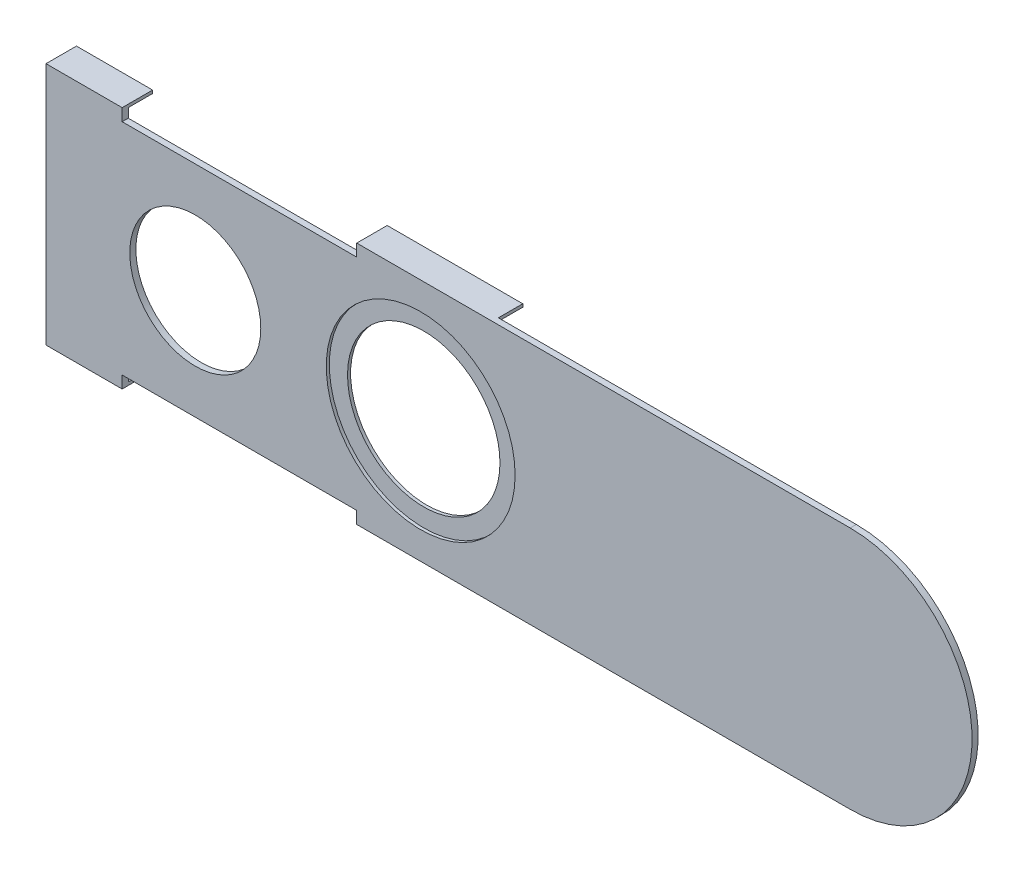
from build123d import *

# Parameters (mm, degrees)
BOSS_EXTRUDE1_DEPTH = 0.508
SKETCH2_R           = 7.874
SKETCH2_R_2         = 6.35
CUT_EXTRUDE2_DEPTH  = 0.254
SKETCH5_R           = 6.354160617
CUT_EXTRUDE3_DEPTH  = 68.821805137
SKETCH6_R           = 5.461
CUT_EXTRUDE4_DEPTH  = 68.821805137
SKETCH7_W           = 19.558
SKETCH7_H           = 1.016
CUT_EXTRUDE5_DEPTH  = 68.823232008
SKETCH8_W           = 6.35
SKETCH8_H           = 0.254
BOSS_EXTRUDE2_DEPTH = 2.032
SKETCH10_W          = 11.303182767
SKETCH10_H          = 0.254
BOSS_EXTRUDE3_DEPTH = 2.032
SKETCH11_W          = 6.35
SKETCH11_H          = 0.254
BOSS_EXTRUDE4_DEPTH = 2.032
SKETCH12_W          = 11.938
SKETCH12_H          = 0.254
BOSS_EXTRUDE5_DEPTH = 2.032
SKETCH13_R          = 7.874
CUT_EXTRUDE7_DEPTH  = 0.254
SKETCH14_R          = 7.874
SKETCH14_R_2        = 5.461
BOSS_EXTRUDE8_DEPTH = 0.254


with BuildPart() as part:
    # Sketch1 → Boss-Extrude1 (new body)
    with BuildSketch(Plane.XY):
        with BuildLine():
            ThreePointArc((0, -10.16), (10.16, 0), (0, 10.16))
            Line((0, 10.16), (-67.056, 10.16))
            Line((-67.056, 10.16), (-67.056, -10.16))
            Line((-67.056, -10.16), (0, -10.16))
        make_face()
    extrude(amount=BOSS_EXTRUDE1_DEPTH)

    # Sketch2 → Cut-Extrude2 (cut)
    with BuildSketch(Plane.XY.offset(0.508)):
        with Locations((-54.61, 0)):
            Circle(SKETCH2_R)
        with Locations((-35.814, 0)):
            Circle(SKETCH2_R_2)
    extrude(amount=-CUT_EXTRUDE2_DEPTH, mode=Mode.SUBTRACT)

    # Sketch5 → Cut-Extrude3 (cut, through all)
    with BuildSketch(Plane.XY.offset(0.254)):
        with Locations((-35.814, 0)):
            Circle(SKETCH5_R)
    extrude(amount=-CUT_EXTRUDE3_DEPTH, mode=Mode.SUBTRACT)

    # Sketch6 → Cut-Extrude4 (cut, through all)
    with BuildSketch(Plane.XY.offset(0.254)):
        with Locations((-54.61, 0)):
            Circle(SKETCH6_R)
    extrude(amount=-CUT_EXTRUDE4_DEPTH, mode=Mode.SUBTRACT)

    # Sketch7 → Cut-Extrude5 (cut, through all)
    with BuildSketch(Plane(origin=(0, 0, 0), x_dir=(-1, 0, 0), z_dir=(0, 0, -1))):
        with Locations((50.927, 9.652)):
            Rectangle(SKETCH7_W, SKETCH7_H)
        with Locations((50.927, -9.652)):
            Rectangle(SKETCH7_W, SKETCH7_H)
    extrude(amount=-CUT_EXTRUDE5_DEPTH, mode=Mode.SUBTRACT)

    # Sketch8 → Boss-Extrude2 (add)
    with BuildSketch(Plane(origin=(0, 0, 0), x_dir=(-1, 0, 0), z_dir=(0, 0, -1))):
        with Locations((63.881, 10.033)):
            Rectangle(SKETCH8_W, SKETCH8_H)
    extrude(amount=BOSS_EXTRUDE2_DEPTH)

    # Sketch10 → Boss-Extrude3 (add)
    with BuildSketch(Plane(origin=(0, 0, 0), x_dir=(-1, 0, 0), z_dir=(0, 0, -1))):
        with Locations((35.496408617, 10.033)):
            Rectangle(SKETCH10_W, SKETCH10_H)
    extrude(amount=BOSS_EXTRUDE3_DEPTH)

    # Sketch11 → Boss-Extrude4 (add)
    with BuildSketch(Plane(origin=(0, 0, 0), x_dir=(-1, 0, 0), z_dir=(0, 0, -1))):
        with Locations((63.881, -10.033)):
            Rectangle(SKETCH11_W, SKETCH11_H)
    extrude(amount=BOSS_EXTRUDE4_DEPTH)

    # Sketch12 → Boss-Extrude5 (add)
    with BuildSketch(Plane(origin=(0, 0, 0), x_dir=(-1, 0, 0), z_dir=(0, 0, -1))):
        with Locations((35.179, -10.033)):
            Rectangle(SKETCH12_W, SKETCH12_H)
    extrude(amount=BOSS_EXTRUDE5_DEPTH)

    # Sketch13 → Cut-Extrude7 (cut)
    with BuildSketch(Plane.XY.offset(0.508)):
        with Locations((-35.814, 0)):
            Circle(SKETCH13_R)
    extrude(amount=-CUT_EXTRUDE7_DEPTH, mode=Mode.SUBTRACT)

    # Sketch14 → Boss-Extrude8 (add)
    with BuildSketch(Plane.XY.offset(0.508)):
        with Locations((-54.61, 0)):
            Circle(SKETCH14_R)
        with Locations((-54.61, 0)):
            Circle(SKETCH14_R_2, mode=Mode.SUBTRACT)
    extrude(amount=-BOSS_EXTRUDE8_DEPTH)


solid = part.part
